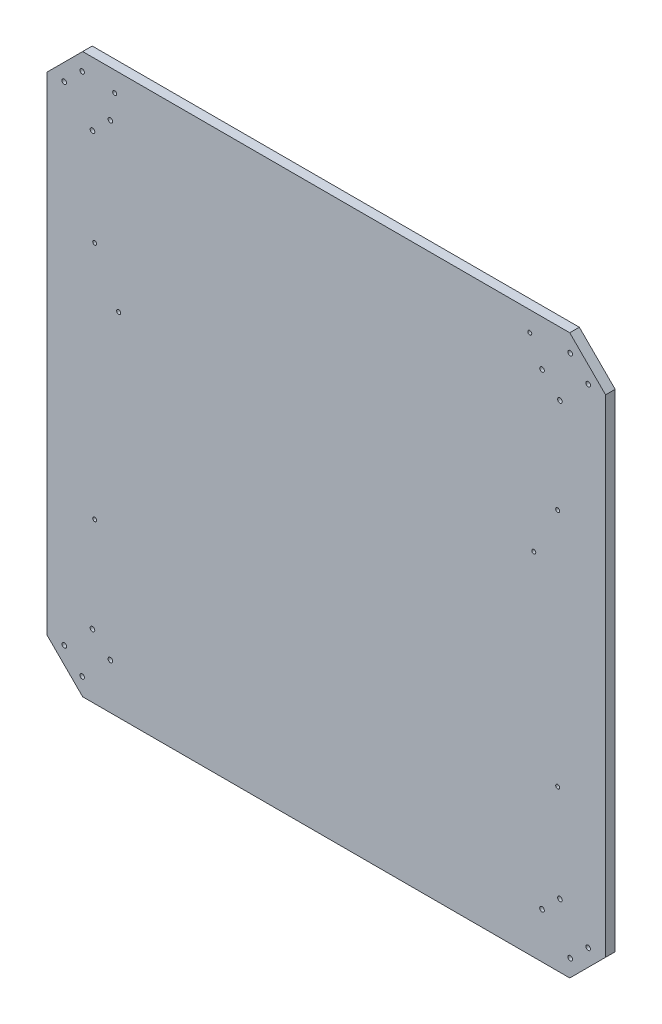
from build123d import *

# Parameters (mm, degrees)
SKETCH1_W           = 700
SKETCH1_H           = 700
BOSS_EXTRUDE1_DEPTH = 12
SKETCH3_R           = 2.891550533
CUT_EXTRUDE2_DEPTH  = 13
SKETCH4_R           = 2.5
CUT_EXTRUDE3_DEPTH  = 20


with BuildPart() as part:
    # Sketch1 → Boss-Extrude1 (new body)
    with BuildSketch(Plane.XY):
        Rectangle(SKETCH1_W, SKETCH1_H)
    extrude(amount=BOSS_EXTRUDE1_DEPTH)

    # Sketch3 → Cut-Extrude2 (cut, through all)
    with BuildSketch(Plane.XY.offset(12)):
        with Locations((305.717437828, 328.168078131)):
            Circle(SKETCH3_R)
        with Locations((328.168078131, 305.717437828)):
            Circle(SKETCH3_R)
        with Locations((292.812739072, 270.362098769)):
            Circle(SKETCH3_R)
        with Locations((270.362098769, 292.812739072)):
            Circle(SKETCH3_R)
        with Locations((-270.362098769, 292.812739072)):
            Circle(SKETCH3_R)
        with Locations((-292.812739072, 270.362098769)):
            Circle(SKETCH3_R)
        with Locations((-305.717437828, 328.168078131)):
            Circle(SKETCH3_R)
        with Locations((-328.168078131, 305.717437828)):
            Circle(SKETCH3_R)
        with Locations((270.362098769, -292.812739072)):
            Circle(SKETCH3_R)
        with Locations((305.717437828, -328.168078131)):
            Circle(SKETCH3_R)
        with Locations((328.168078131, -305.717437828)):
            Circle(SKETCH3_R)
        with Locations((292.812739072, -270.362098769)):
            Circle(SKETCH3_R)
        with Locations((-270.362098769, -292.812739072)):
            Circle(SKETCH3_R)
        with Locations((-292.812739072, -270.362098769)):
            Circle(SKETCH3_R)
        with Locations((-305.717437828, -328.168078131)):
            Circle(SKETCH3_R)
        with Locations((-328.168078131, -305.717437828)):
            Circle(SKETCH3_R)
        Polygon((350, 350), (305.098719395, 350), (350, 305.098719395), align=None)
        Polygon((-305.098719395, 350), (-350, 305.098719395), (-350, 350), align=None)
        Polygon((305.098719395, -350), (350, -305.098719395), (350, -350), align=None)
        Polygon((-350, -350), (-305.098719395, -350), (-350, -305.098719395), align=None)
    extrude(amount=-CUT_EXTRUDE2_DEPTH, mode=Mode.SUBTRACT)

    # Sketch4 → Cut-Extrude3 (cut)
    with BuildSketch(Plane.XY.offset(12)):
        with Locations((-290, 150)):
            Circle(SKETCH4_R)
        with Locations((290, 150)):
            Circle(SKETCH4_R)
        with Locations((290, -150)):
            Circle(SKETCH4_R)
        with Locations((-290, -150)):
            Circle(SKETCH4_R)
        with Locations((-265, 325)):
            Circle(SKETCH4_R)
        with Locations((255, 325)):
            Circle(SKETCH4_R)
        with Locations((-260, 90)):
            Circle(SKETCH4_R)
        with Locations((260, 90)):
            Circle(SKETCH4_R)
    extrude(amount=-CUT_EXTRUDE3_DEPTH, mode=Mode.SUBTRACT)


solid = part.part
